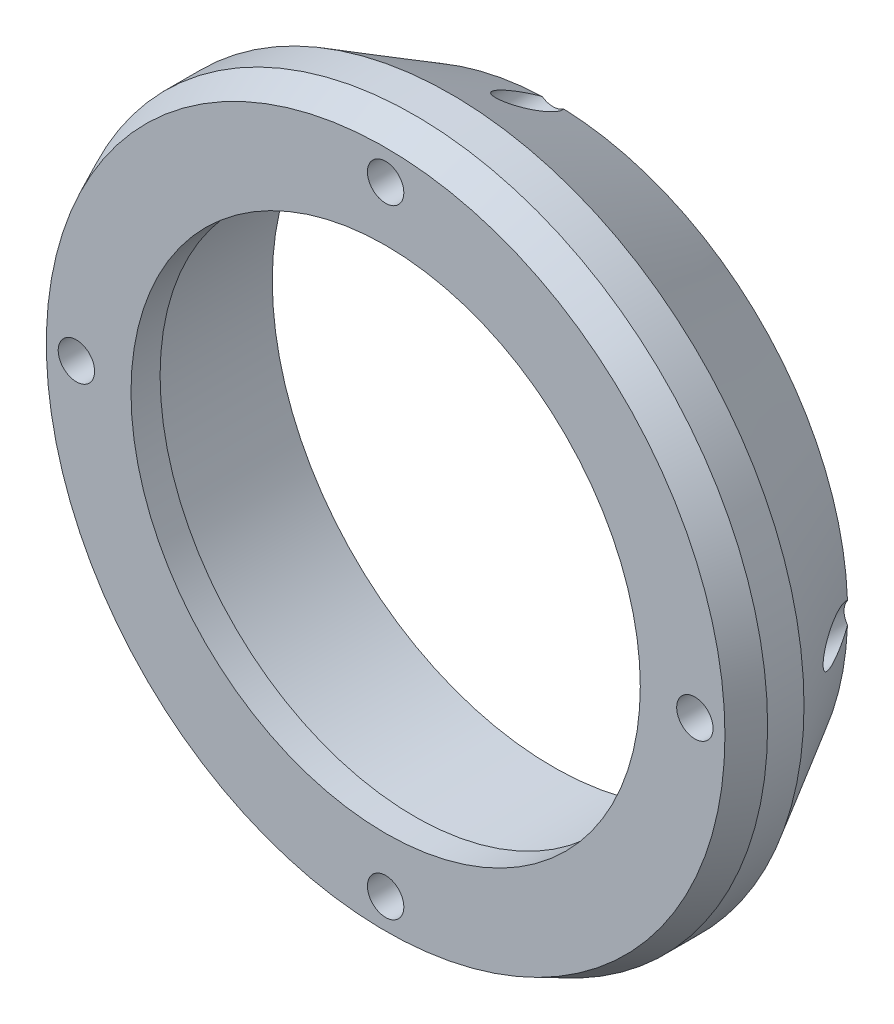
from build123d import *

# Parameters (mm, degrees)
SKETCH1_R                   = 61.595
SKETCH1_R_2                 = 44.45
EXTRUDE1_DEPTH              = 29.21
SKETCH2_R                   = 49
EXTRUDE2_DEPTH              = 24.13
CHAMFER2_SIZE               = 10.16
CHAMFER2_SIZE2              = 17.78
F_1_4_0_25_DIAMETER_HOLE1_D = 6.35
CIRPATTERN1_COUNT           = 4
CHAMFER1_SIZE               = 5.08
CHAMFER1_SIZE2              = 2.368842903


with BuildPart() as part:
    # Sketch1 → Extrude1 (new body)
    with BuildSketch(Plane.XY):
        Circle(SKETCH1_R)
        Circle(SKETCH1_R_2, mode=Mode.SUBTRACT)
    extrude(amount=EXTRUDE1_DEPTH)

    # Sketch2 → Extrude2 (cut)
    with BuildSketch(Plane(origin=(0, 0, 0), x_dir=(-1, 0, 0), z_dir=(0, 0, -1))):
        Circle(SKETCH2_R)
    extrude(amount=-EXTRUDE2_DEPTH, mode=Mode.SUBTRACT)

    # Chamfer2
    chamfer2_edges = [part.edges().sort_by_distance(p)[0] for p in [
        (-61.595, 0, 0),
    ]]
    chamfer2_side = [part.faces().sort_by_distance(p)[0] for p in [
        (-59.852830313, 0, 0),
    ]]
    chamfer(chamfer2_edges, length=CHAMFER2_SIZE, length2=CHAMFER2_SIZE2, reference=chamfer2_side[0])

    # 1/4 (0.25) Diameter Hole1 (through all)
    with Locations(Plane.XY.offset(29.21)):
        with Locations((0, 53.975)):
            f_1_4_0_25_diameter_hole1 = Hole(F_1_4_0_25_DIAMETER_HOLE1_D / 2)

    # CirPattern1: 1/4 (0.25) Diameter Hole1 ×4 about axis
    cirpattern1_axis = Axis((0, 0, 0), (0, 0, 1))
    for i in range(1, CIRPATTERN1_COUNT):
        add(f_1_4_0_25_diameter_hole1.rotate(cirpattern1_axis, i * 360 / CIRPATTERN1_COUNT), mode=Mode.SUBTRACT)

    # Chamfer1
    chamfer1_edges = [part.edges().sort_by_distance(p)[0] for p in [
        (-61.595, 0, 29.21),
    ]]
    chamfer1_side = [part.faces().sort_by_distance(p)[0] for p in [
        (-61.595, 0, 23.495),
    ]]
    chamfer(chamfer1_edges, length=CHAMFER1_SIZE, length2=CHAMFER1_SIZE2, reference=chamfer1_side[0])


solid = part.part
